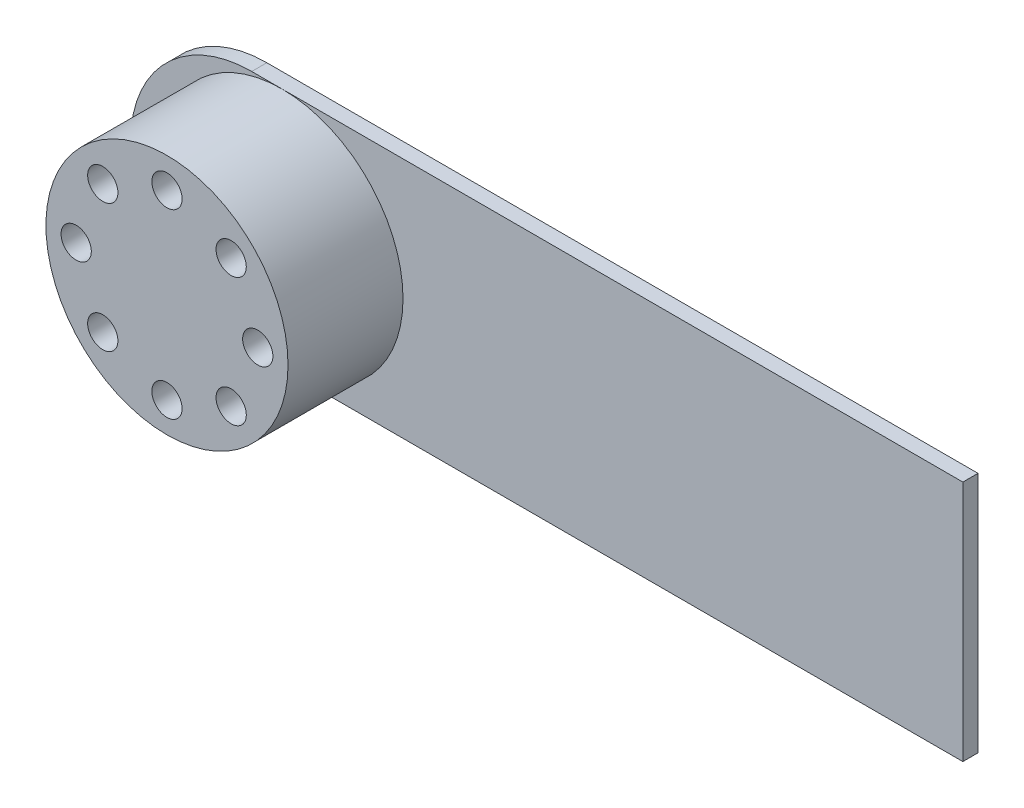
from build123d import *

# Parameters (mm, degrees)
AUFSATZ_LINEAR_AUSTRAGEN1_DEPTH = 0.1
SKIZZE2_R                       = 0.8
AUFSATZ_LINEAR_AUSTRAGEN2_DEPTH = 0.76
DURCHGANGSLOCH_F_R_M1_41_D      = 0.2
DURCHGANGSLOCH_F_R_M1_41_DEPTH  = 0.4
KREISMUSTER5_COUNT              = 8


with BuildPart() as part:
    # Skizze1 → Aufsatz-Linear austragen1 (new body)
    with BuildSketch(Plane.XY):
        with BuildLine():
            Line((0, 0), (-4.7, 0))
            ThreePointArc((-4.7, 0), (-5.5, 0.8), (-4.7, 1.6))
            Line((-4.7, 1.6), (0, 1.6))
            Line((0, 1.6), (0, 0))
        make_face()
    extrude(amount=AUFSATZ_LINEAR_AUSTRAGEN1_DEPTH)

    # Skizze2 → Aufsatz-Linear austragen2 (add)
    with BuildSketch(Plane.XY.offset(0.1)):
        with Locations(Location((-4.5, 0.8, 0), (0, 0, 270))):  # turned: the seam where the file's is
            Circle(SKIZZE2_R)
    extrude(amount=AUFSATZ_LINEAR_AUSTRAGEN2_DEPTH)

    # Durchgangsloch für M1.41
    with Locations(Plane(origin=(-4.5, 1.4, 0.86), x_dir=(1, 0, 0), z_dir=(0, 0, 1))):
        with Locations((0, 0)):
            durchgangsloch_f_r_m1_41 = Hole(DURCHGANGSLOCH_F_R_M1_41_D / 2, depth=DURCHGANGSLOCH_F_R_M1_41_DEPTH)

    # Kreismuster5: Durchgangsloch für M1.41 ×8 about axis
    kreismuster5_axis = Axis((-4.5, 0.8, 0), (0, 0, 1))
    for i in range(1, KREISMUSTER5_COUNT):
        add(durchgangsloch_f_r_m1_41.rotate(kreismuster5_axis, i * 360 / KREISMUSTER5_COUNT), mode=Mode.SUBTRACT)


solid = part.part
